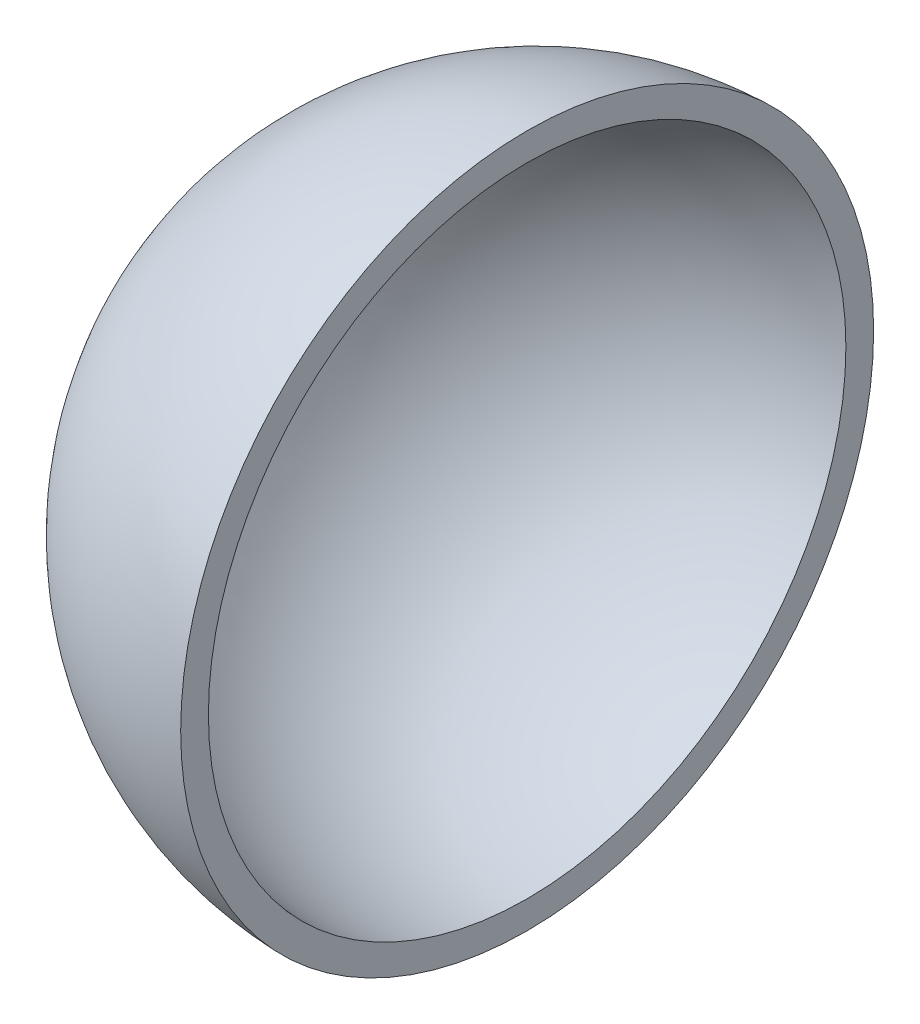
from build123d import *


with BuildPart() as part:
    # 草图1 → 旋转1 (revolve)
    with BuildSketch(Plane(origin=(0, 0, 0), x_dir=(1, 0, 0), z_dir=(0, 1, 0))):
        with BuildLine():
            Line((-34.5, 0), (-37.5, 0))
            ThreePointArc((-37.5, 0), (-26.867731575, -26.160561921), (-1, -37.486664295))
            Line((-1, -37.486664295), (-1, -34.485504201))
            ThreePointArc((-1, -34.485504201), (-24.746211831, -24.039030762), (-34.5, 0))
        make_face()
    revolve(axis=Axis((0, 0, 0), (-1, 0, 0)))


solid = part.part
